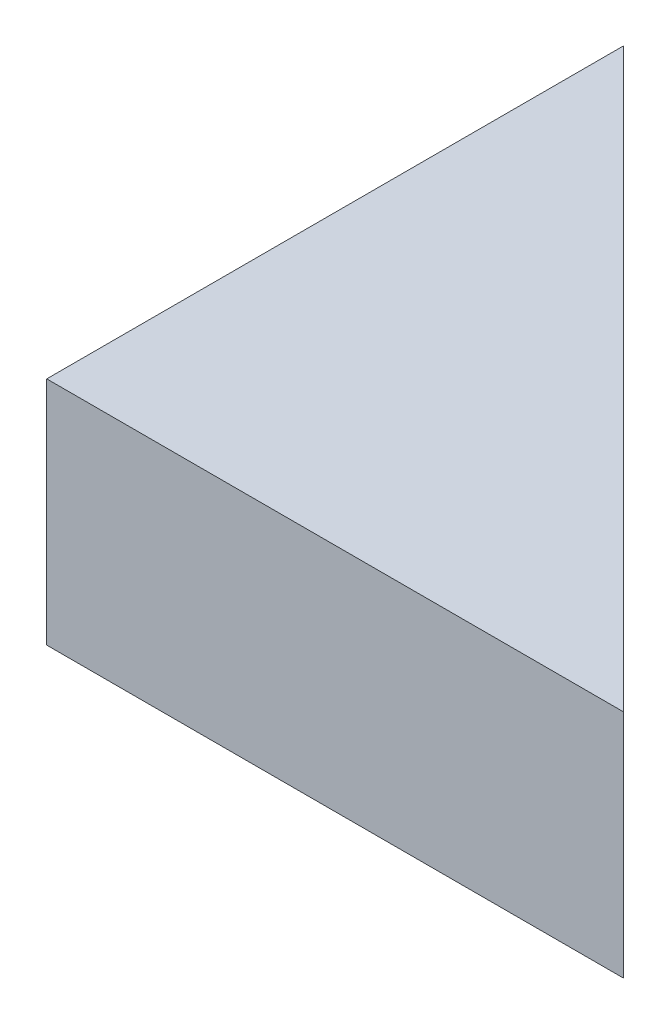
from build123d import *

# Parameters (mm, degrees)
SALIENTE_EXTRUIR1_DEPTH = 200


with BuildPart() as part:
    # Croquis1 → Saliente-Extruir1 (new body)
    with BuildSketch(Plane(origin=(0, 0, 0), x_dir=(1, 0, 0), z_dir=(0, 1, 0))):
        Polygon((0, 0), (0, 500), (500, 0), align=None)
    extrude(amount=SALIENTE_EXTRUIR1_DEPTH)


solid = part.part
